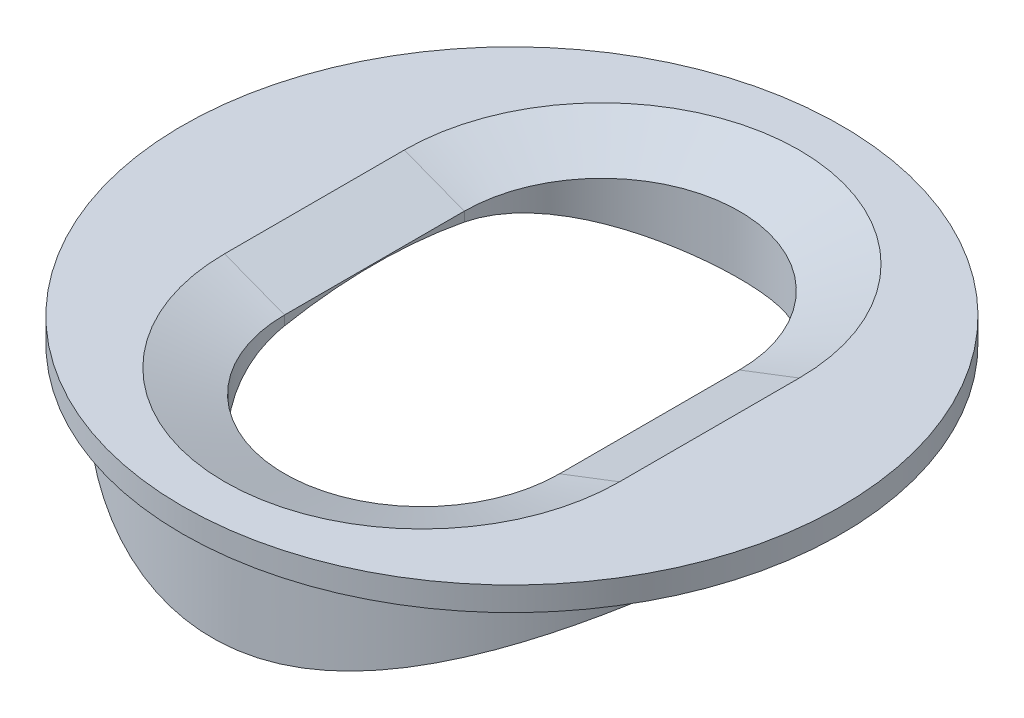
from build123d import *

# Parameters (mm, degrees)
SKETCH1_R               = 5
BOSS_EXTRUDE1_DEPTH     = 5
SKETCH2_R               = 5.5
BOSS_EXTRUDE2_DEPTH     = 0.4
CUT_EXTRUDE1_DEPTH      = 6.4
SKETCH5_R               = 8
CUT_EXTRUDE2_DEPTH      = 6.5
CUT_EXTRUDE2_DEPTH_BACK = 6.5
CHAMFER4_SIZE           = 1
CHAMFER4_SIZE2          = 0.383864035


with BuildPart() as part:
    # Sketch1 → Boss-Extrude1 (new body)
    with BuildSketch(Plane(origin=(0, 0, 0), x_dir=(1, 0, 0), z_dir=(0, 1, 0))):
        Circle(SKETCH1_R)
    extrude(amount=BOSS_EXTRUDE1_DEPTH)

    # Sketch2 → Boss-Extrude2 (add)
    with BuildSketch(Plane(origin=(0, 5, 0), x_dir=(1, 0, 0), z_dir=(0, 1, 0))):
        Circle(SKETCH2_R)
    extrude(amount=BOSS_EXTRUDE2_DEPTH)

    # Sketch4 → Cut-Extrude1 (cut, through all)
    with BuildSketch(Plane(origin=(0, 5.4, 0), x_dir=(1, 0, 0), z_dir=(0, 1, 0))):
        with BuildLine():
            Line((2.295250379, 1.5), (2.295250379, -1.5))
            ThreePointArc((2.295250379, -1.5), (0, -3.795250379), (-2.295250379, -1.5))
            Line((-2.295250379, -1.5), (-2.295250379, 1.5))
            ThreePointArc((-2.295250379, 1.5), (0, 3.795250379), (2.295250379, 1.5))
        make_face()
    extrude(amount=-CUT_EXTRUDE1_DEPTH, mode=Mode.SUBTRACT)

    # Sketch5 → Cut-Extrude2 (cut, two sides)
    with BuildSketch(Plane(origin=(0, 0, 0), x_dir=(0, 0, -1), z_dir=(1, 0, 0))) as cut_extrude2_sk:
        with Locations((0, -3)):
            Circle(SKETCH5_R)
    extrude(amount=CUT_EXTRUDE2_DEPTH, mode=Mode.SUBTRACT)
    extrude(cut_extrude2_sk.sketch, amount=-CUT_EXTRUDE2_DEPTH_BACK, mode=Mode.SUBTRACT)

    # Chamfer4
    chamfer4_edges = [part.edges().sort_by_distance(p)[0] for p in [
        (0, 5.4, -3.795250379),
        (-2.295250379, 5.4, 0),
        (0, 5.4, 3.795250379),
        (2.295250379, 5.4, 0),
    ]]
    chamfer4_side = [part.faces().sort_by_distance(p)[0] for p in [
        (-5.344436508, 5.4, 0),
    ]]
    chamfer(chamfer4_edges, length=CHAMFER4_SIZE, length2=CHAMFER4_SIZE2, reference=chamfer4_side[0])


solid = part.part
